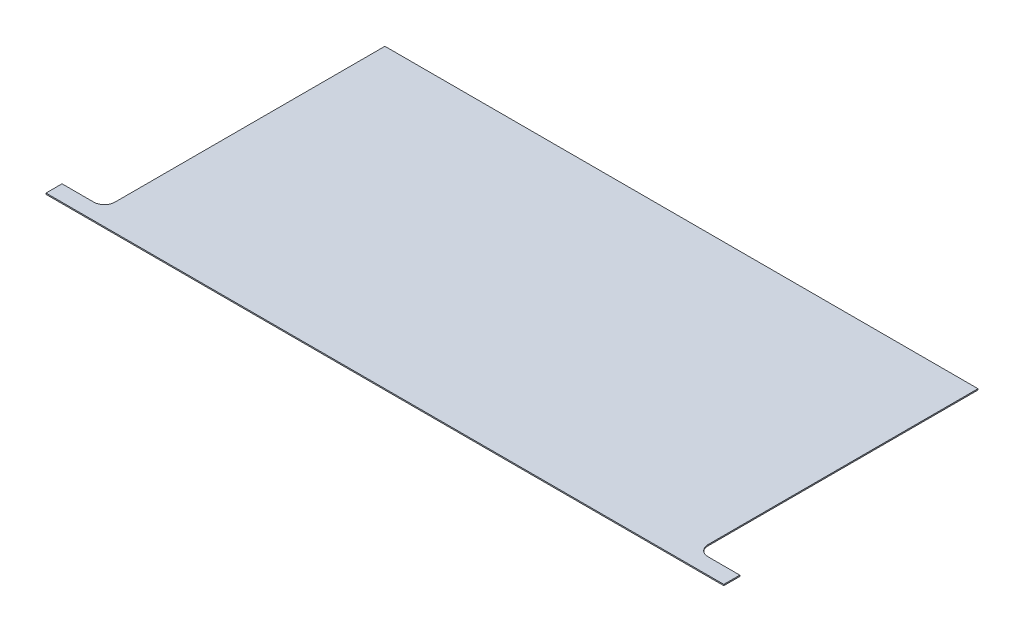
from build123d import *

# Parameters (mm, degrees)
BOSS_EXTRUDE1_DEPTH = 0.3556
FILLET3_R           = 3.175


with BuildPart() as part:
    # Sketch1 → Boss-Extrude1 (new body)
    with BuildSketch(Plane(origin=(0, 0, 0), x_dir=(1, 0, 0), z_dir=(0, 1, 0))):
        Polygon((12.7, 88.9), (12.7, 4.8), (0, 4.8), (0, 0), (12.7, 0), (190.5, 0), (203.2, 0), (203.2, 4.8), (190.5, 4.8), (190.5, 88.9), align=None)
    extrude(amount=BOSS_EXTRUDE1_DEPTH)

    # Fillet3
    fillet3_edges = [part.edges().sort_by_distance(p)[0] for p in [
        (12.7, 0.1778, -4.8),
        (190.5, 0.1778, -4.8),
    ]]
    fillet(fillet3_edges, radius=FILLET3_R)


solid = part.part
